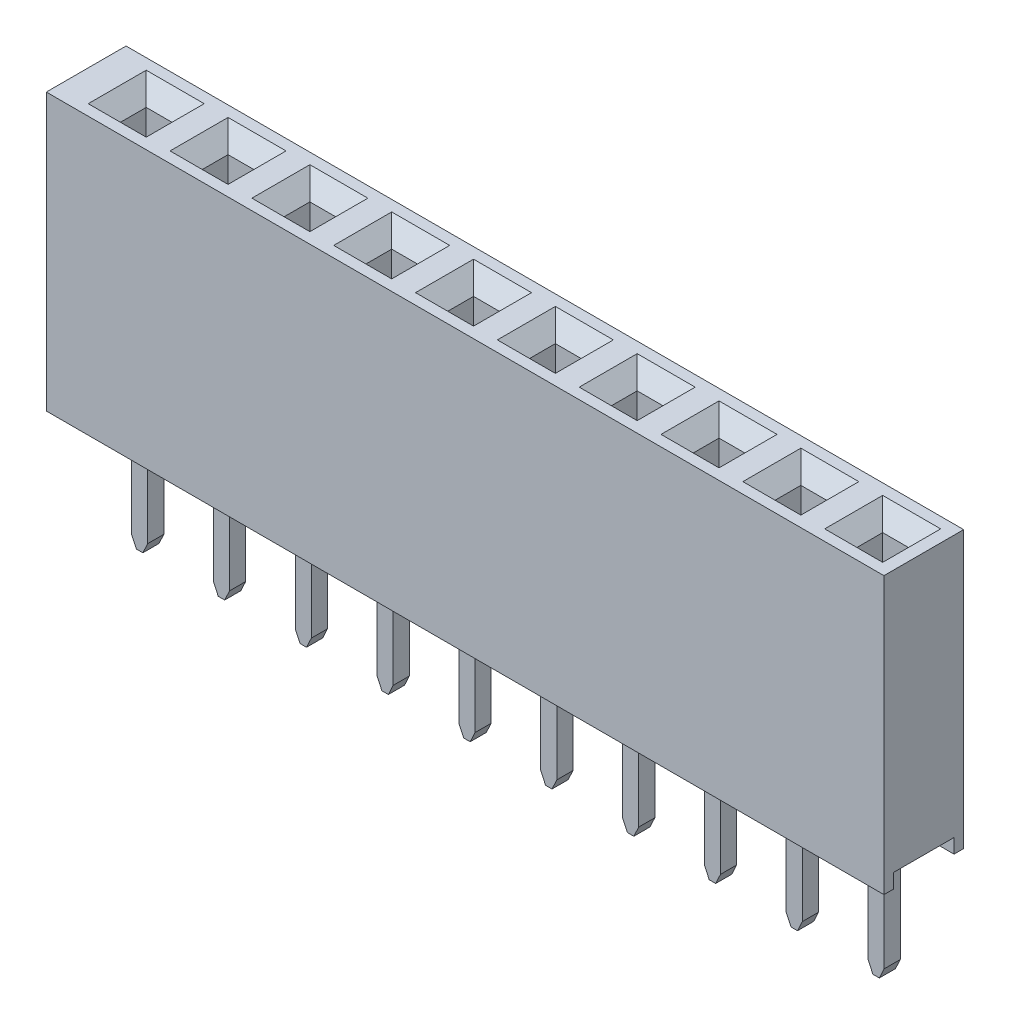
from build123d import *

# Parameters (mm, degrees)
SKETCH1_W                  = 26
SKETCH1_H                  = 8.575
BOSS_EXTRUDE1_DEPTH        = 1.2375
SKETCH2_W                  = 1.875
SKETCH2_H                  = 0.447874384
CUT_EXTRUDE1_DEPTH         = 50
SKETCH4_W                  = 0.8
SKETCH4_H                  = 0.8
CUT_EXTRUDE2_DEPTH         = 1.5
CHAMFER1_SIZE              = 0.5
SKETCH5_W                  = 1.8
SKETCH5_H                  = 1.8
CUT_EXTRUDE3_DEPTH         = 3
BOSS_EXTRUDE4_DEPTH        = 0.85
BOSS_EXTRUDE5_DEPTH        = 0.25
LPATTERN1_COUNT            = 10
LPATTERN1_PITCH            = 2.54
CHAMFER1_OF_LPATTERN1_SIZE = 0.5


with BuildPart() as part:
    # Sketch1 → Boss-Extrude1 (new, symmetric)
    with BuildSketch(Plane.XY):
        Rectangle(SKETCH1_W, SKETCH1_H)
    extrude(amount=BOSS_EXTRUDE1_DEPTH, both=True)

    # Sketch2 → Cut-Extrude1 (cut, symmetric)
    with BuildSketch(Plane(origin=(0, 0, 0), x_dir=(0, 0, -1), z_dir=(1, 0, 0))):
        with Locations((0, -4.063562808)):
            Rectangle(SKETCH2_W, SKETCH2_H)
    extrude(amount=CUT_EXTRUDE1_DEPTH, both=True, mode=Mode.SUBTRACT)

    # Sketch4 → Cut-Extrude2 (cut)
    with BuildSketch(Plane(origin=(0, 4.2875, 0), x_dir=(1, 0, 0), z_dir=(0, 1, 0))):
        with Locations((-11.136635508, 0)):
            Rectangle(SKETCH4_W, SKETCH4_H)
    cut_extrude2 = extrude(amount=-CUT_EXTRUDE2_DEPTH, mode=Mode.SUBTRACT)

    # Chamfer1
    chamfer1_edges = [part.edges().sort_by_distance(p)[0] for p in [
        (-11.136635508, 4.2875, -0.4),
        (-11.536635508, 4.2875, 0),
        (-11.136635508, 4.2875, 0.4),
        (-10.736635508, 4.2875, 0),
    ]]
    chamfer(chamfer1_edges, length=CHAMFER1_SIZE)

    # Sketch5 → Cut-Extrude3 (cut, symmetric)
    with BuildSketch(Plane(origin=(0, 0, 0), x_dir=(1, 0, 0), z_dir=(0, 1, 0))):
        with Locations((-11.136635508, 0)):
            Rectangle(SKETCH5_W, SKETCH5_H)
    cut_extrude3 = extrude(amount=CUT_EXTRUDE3_DEPTH, both=True, mode=Mode.SUBTRACT)

    # Sketch9 → Boss-Extrude4 (add, symmetric)
    with BuildSketch(Plane.XY):
        with BuildLine():
            ThreePointArc((-10.582814426, -1.938025879), (-10.728576084, -2.279011767), (-11.09032001, -2.3606155))
            ThreePointArc((-11.09032001, -2.3606155), (-11.452063935, -2.279011767), (-11.597825593, -1.938025879))
            Line((-11.597825593, -1.938025879), (-11.370601274, 1.372957064))
            ThreePointArc((-11.370601274, 1.372957064), (-11.252905149, 1.609785424), (-11.503591816, 1.525546213))
            Line((-11.503591816, 1.525546213), (-11.692506396, -1.227209088))
            Line((-11.692506396, -1.227209088), (-11.943085855, -1.307980897))
            Line((-11.943085855, -1.307980897), (-11.943085855, -2.65963841))
            Line((-11.943085855, -2.65963841), (-11.371048299, -3.019652953))
            Line((-11.371048299, -3.019652953), (-10.809591721, -3.019652953))
            Line((-10.809591721, -3.019652953), (-10.237554165, -2.65963841))
            Line((-10.237554165, -2.65963841), (-10.237554165, -1.307980897))
            Line((-10.237554165, -1.307980897), (-10.488133624, -1.227209088))
            Line((-10.488133624, -1.227209088), (-10.677048203, 1.525546213))
            ThreePointArc((-10.677048203, 1.525546213), (-10.927734871, 1.609785424), (-10.810038746, 1.372957064))
            Line((-10.810038746, 1.372957064), (-10.582814426, -1.938025879))
        make_face()
    boss_extrude4 = extrude(amount=BOSS_EXTRUDE4_DEPTH, both=True)

    # Sketch9_3 → Boss-Extrude5 (add, symmetric)
    with BuildSketch(Plane.XY):
        Polygon((-10.84032001, -7.265823962), (-10.84032001, -3.019652953), (-11.34032001, -3.019652953), (-11.34032001, -7.265823962), (-11.19032001, -7.5875), (-10.99032001, -7.5875), align=None)
    boss_extrude5 = extrude(amount=BOSS_EXTRUDE5_DEPTH, both=True)

    # LPattern1: Cut-Extrude2, Cut-Extrude3, Boss-Extrude4, Boss-Extrude5 ×10
    with Locations(*[(i * LPATTERN1_PITCH, 0, 0) for i in range(1, LPATTERN1_COUNT)]):
        add(cut_extrude2, mode=Mode.SUBTRACT)
        add(cut_extrude3, mode=Mode.SUBTRACT)
        add(boss_extrude4)
        add(boss_extrude5)

    # Chamfer1 of LPattern1
    chamfer1_of_lpattern1_edges = [part.edges().sort_by_distance(p)[0] for p in [
        (-8.596635508, 4.2875, -0.4),
        (-8.996635508, 4.2875, 0),
        (-8.596635508, 4.2875, 0.4),
        (-8.196635508, 4.2875, 0),
        (-6.056635508, 4.2875, -0.4),
        (-6.456635508, 4.2875, 0),
        (-6.056635508, 4.2875, 0.4),
        (-5.656635508, 4.2875, 0),
        (-3.516635508, 4.2875, -0.4),
        (-3.916635508, 4.2875, 0),
        (-3.516635508, 4.2875, 0.4),
        (-3.116635508, 4.2875, 0),
        (-0.976635508, 4.2875, -0.4),
        (-1.376635508, 4.2875, 0),
        (-0.976635508, 4.2875, 0.4),
        (-0.576635508, 4.2875, 0),
        (1.563364492, 4.2875, -0.4),
        (1.163364492, 4.2875, 0),
        (1.563364492, 4.2875, 0.4),
        (1.963364492, 4.2875, 0),
        (4.103364492, 4.2875, -0.4),
        (3.703364492, 4.2875, 0),
        (4.103364492, 4.2875, 0.4),
        (4.503364492, 4.2875, 0),
        (6.643364492, 4.2875, -0.4),
        (6.243364492, 4.2875, 0),
        (6.643364492, 4.2875, 0.4),
        (7.043364492, 4.2875, 0),
        (9.183364492, 4.2875, -0.4),
        (8.783364492, 4.2875, 0),
        (9.183364492, 4.2875, 0.4),
        (9.583364492, 4.2875, 0),
        (11.723364492, 4.2875, -0.4),
        (11.323364492, 4.2875, 0),
        (11.723364492, 4.2875, 0.4),
        (12.123364492, 4.2875, 0),
    ]]
    chamfer(chamfer1_of_lpattern1_edges, length=CHAMFER1_OF_LPATTERN1_SIZE)


solid = part.part
